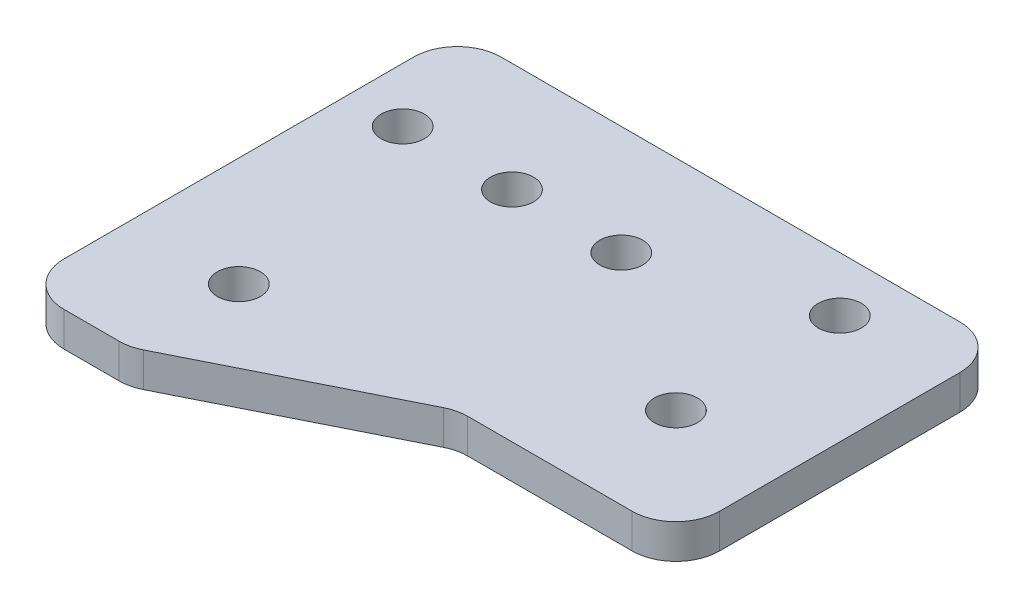
from build123d import *

# Parameters (mm, degrees)
SKETCH1_R           = 2.5
BOSS_EXTRUDE1_DEPTH = 4
FILLET1_R           = 5.08


with BuildPart() as part:
    # Sketch1 → Boss-Extrude1 (new body)
    with BuildSketch(Plane.XZ):
        Polygon((127, 38.1), (101.6, 38.1), (76.2, 50.8), (63.5, 50.8), (63.5, 0), (127, 0), align=None)
        with Locations((69.85, 12.7)):
            Circle(SKETCH1_R, mode=Mode.SUBTRACT)
        with Locations((82.55, 12.7)):
            Circle(SKETCH1_R, mode=Mode.SUBTRACT)
        with Locations((114.3, 6.35)):
            Circle(SKETCH1_R, mode=Mode.SUBTRACT)
        with Locations((95.25, 12.7)):
            Circle(SKETCH1_R, mode=Mode.SUBTRACT)
        with Locations((114.3, 25.4)):
            Circle(SKETCH1_R, mode=Mode.SUBTRACT)
        with Locations((76.2, 38.1)):
            Circle(SKETCH1_R, mode=Mode.SUBTRACT)
    extrude(amount=BOSS_EXTRUDE1_DEPTH)

    # Fillet1
    fillet1_edges = [part.edges().sort_by_distance(p)[0] for p in [
        (63.5, -2, 50.8),
        (76.2, -2, 50.8),
        (101.6, -2, 38.1),
        (127, -2, 38.1),
        (127, -2, 0),
        (63.5, -2, 0),
    ]]
    fillet(fillet1_edges, radius=FILLET1_R)


solid = part.part
